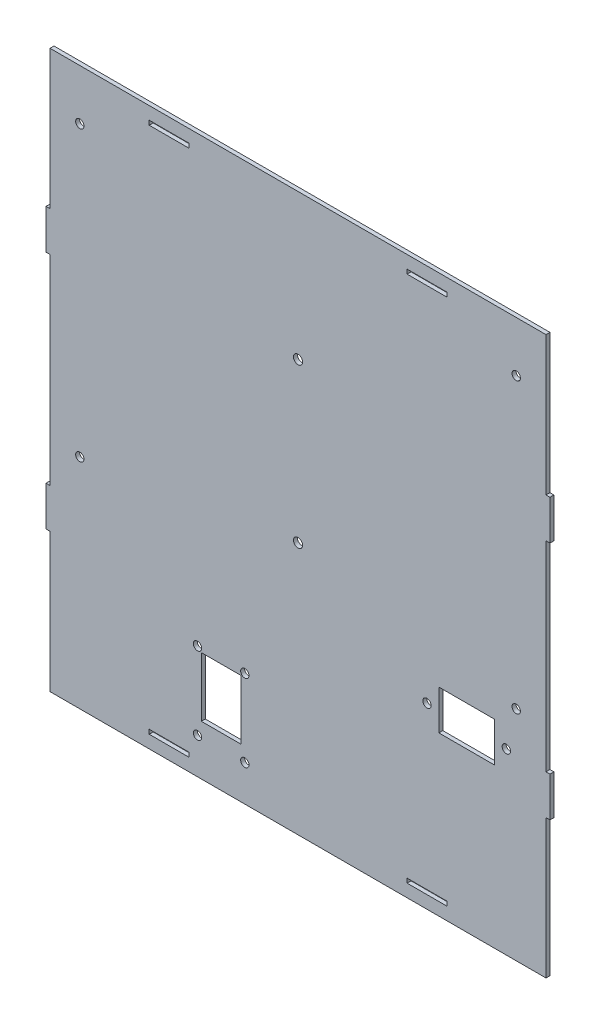
from build123d import *

# Parameters (mm, degrees)
SKETCH1_W           = 250
SKETCH1_H           = 280.866666666
SKETCH1_R           = 2.3
SKETCH1_W_2         = 20
SKETCH1_H_2         = 2.2
BOSS_EXTRUDE1_DEPTH = 2
SKETCH2_W           = 2
SKETCH2_H           = 20
BOSS_EXTRUDE2_DEPTH = 2
SKETCH3_R           = 2.1
SKETCH3_W           = 28
SKETCH3_H           = 20
CUT_EXTRUDE1_DEPTH  = 5
SKETCH4_W           = 20
SKETCH4_H           = 30
CUT_EXTRUDE2_DEPTH  = 5
SKETCH5_R           = 2.1
CUT_EXTRUDE3_DEPTH  = 3
SKETCH6_R           = 2.1
CUT_EXTRUDE4_DEPTH  = 5
SKETCH7_R           = 2.1
CUT_EXTRUDE5_DEPTH  = 5


with BuildPart() as part:
    # Sketch1 → Boss-Extrude1 (new body)
    with BuildSketch(Plane.XY):
        with Locations((125, 135)):
            Rectangle(SKETCH1_W, SKETCH1_H)
        with Locations((125, 122.1)):
            Circle(SKETCH1_R, mode=Mode.SUBTRACT)
        with Locations((125, 202.1)):
            Circle(SKETCH1_R, mode=Mode.SUBTRACT)
        with Locations((190, 2.066666667)):
            Rectangle(SKETCH1_W_2, SKETCH1_H_2, mode=Mode.SUBTRACT)
        with Locations((60, 2.066666667)):
            Rectangle(SKETCH1_W_2, SKETCH1_H_2, mode=Mode.SUBTRACT)
        with Locations((190, 267.933333333)):
            Rectangle(SKETCH1_W_2, SKETCH1_H_2, mode=Mode.SUBTRACT)
        with Locations((60, 267.933333333)):
            Rectangle(SKETCH1_W_2, SKETCH1_H_2, mode=Mode.SUBTRACT)
    extrude(amount=BOSS_EXTRUDE1_DEPTH)

    # Sketch2 → Boss-Extrude2 (add)
    with BuildSketch(Plane.XY.offset(2)):
        with Locations((-1, 195.433333333)):
            Rectangle(SKETCH2_W, SKETCH2_H)
        with Locations((-1, 74.566666667)):
            Rectangle(SKETCH2_W, SKETCH2_H)
        with Locations((251, 195.433333333)):
            Rectangle(SKETCH2_W, SKETCH2_H)
        with Locations((251, 74.566666667)):
            Rectangle(SKETCH2_W, SKETCH2_H)
    extrude(amount=-BOSS_EXTRUDE2_DEPTH)

    # Sketch3 → Cut-Extrude1 (cut)
    with BuildSketch(Plane.XY.offset(2)):
        with Locations((190, 84.566666667)):
            Circle(SKETCH3_R)
        with Locations((230, 84.566666667)):
            Circle(SKETCH3_R)
        with Locations((210, 84.566666667)):
            Rectangle(SKETCH3_W, SKETCH3_H)
    extrude(amount=-CUT_EXTRUDE1_DEPTH, mode=Mode.SUBTRACT)

    # Sketch4 → Cut-Extrude2 (cut)
    with BuildSketch(Plane.XY.offset(2)):
        with Locations((86.25, 34.766666667)):
            Rectangle(SKETCH4_W, SKETCH4_H)
    extrude(amount=-CUT_EXTRUDE2_DEPTH, mode=Mode.SUBTRACT)

    # Sketch5 → Cut-Extrude3 (cut, through all)
    with BuildSketch(Plane.XY.offset(2)):
        with Locations((98.18627451, 12.72)):
            Circle(SKETCH5_R)
        with Locations((74.31372549, 12.72)):
            Circle(SKETCH5_R)
        with Locations((74.31372549, 51.68)):
            Circle(SKETCH5_R)
        with Locations((98.18627451, 51.68)):
            Circle(SKETCH5_R)
    extrude(amount=-CUT_EXTRUDE3_DEPTH, mode=Mode.SUBTRACT)

    # Sketch6 → Cut-Extrude4 (cut)
    with BuildSketch(Plane.XY.offset(2)):
        with Locations((235, 250)):
            Circle(SKETCH6_R)
        with Locations((15, 250)):
            Circle(SKETCH6_R)
    extrude(amount=-CUT_EXTRUDE4_DEPTH, mode=Mode.SUBTRACT)

    # Sketch7 → Cut-Extrude5 (cut)
    with BuildSketch(Plane.XY.offset(2)):
        with Locations((15, 104.566666667)):
            Circle(SKETCH7_R)
        with Locations((235, 104.566666667)):
            Circle(SKETCH7_R)
    extrude(amount=-CUT_EXTRUDE5_DEPTH, mode=Mode.SUBTRACT)


solid = part.part
